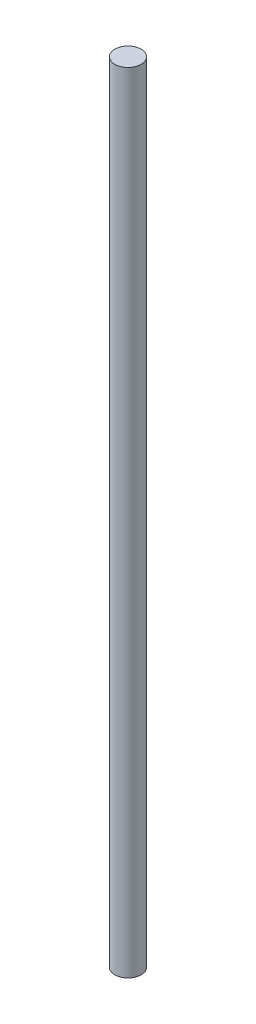
from build123d import *

# Parameters (mm, degrees)
CROQUIS1_R              = 0.25
SALIENTE_EXTRUIR1_DEPTH = 15


with BuildPart() as part:
    # Croquis1 → Saliente-Extruir1 (new body)
    with BuildSketch(Plane(origin=(0, 0, 0), x_dir=(1, 0, 0), z_dir=(0, 1, 0))):
        Circle(CROQUIS1_R)
    extrude(amount=SALIENTE_EXTRUIR1_DEPTH)


solid = part.part
